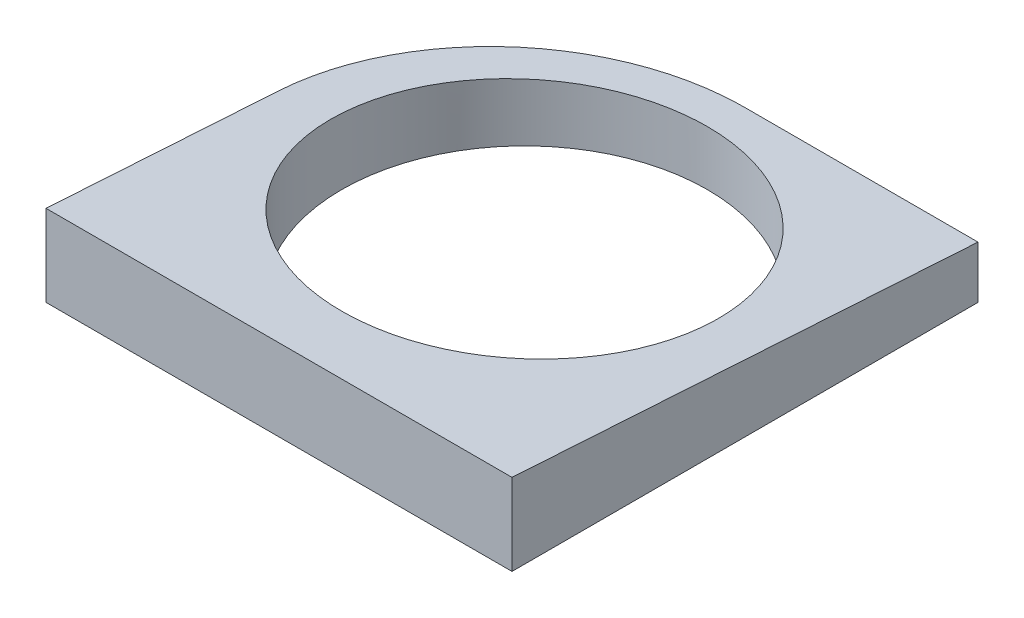
from build123d import *

# Parameters (mm, degrees)
SKETCH1_R           = 17.5
BOSS_EXTRUDE1_DEPTH = 300
CUT_EXTRUDE1_DEPTH  = 150


with BuildPart() as part:
    # Sketch1 → Boss-Extrude1 (new body)
    with BuildSketch(Plane(origin=(0, 0, 0), x_dir=(1, 0, 0), z_dir=(0, 1, 0))):
        with BuildLine():
            Line((-22.3, -23.5), (22.3, -23.5))
            Line((22.3, -23.5), (22.3, 21.1))
            Line((22.3, 21.1), (0, 21.1))
            ThreePointArc((0, 21.1), (-15.76848122, 14.56848122), (-22.3, -1.2))
            Line((-22.3, -1.2), (-22.3, -23.5))
        make_face()
        Circle(SKETCH1_R, mode=Mode.SUBTRACT)
    extrude(amount=BOSS_EXTRUDE1_DEPTH)

    # Sketch2 → Cut-Extrude1 (cut, symmetric)
    with BuildSketch(Plane(origin=(0, 0, 0), x_dir=(0, 0, -1), z_dir=(1, 0, 0))):
        Polygon((-23.5, 7.8), (21.1, 5), (89.895743618, 5), (89.895743618, 331.939309381), (-23.5, 331.939309381), align=None)
    extrude(amount=CUT_EXTRUDE1_DEPTH, both=True, mode=Mode.SUBTRACT)


solid = part.part
